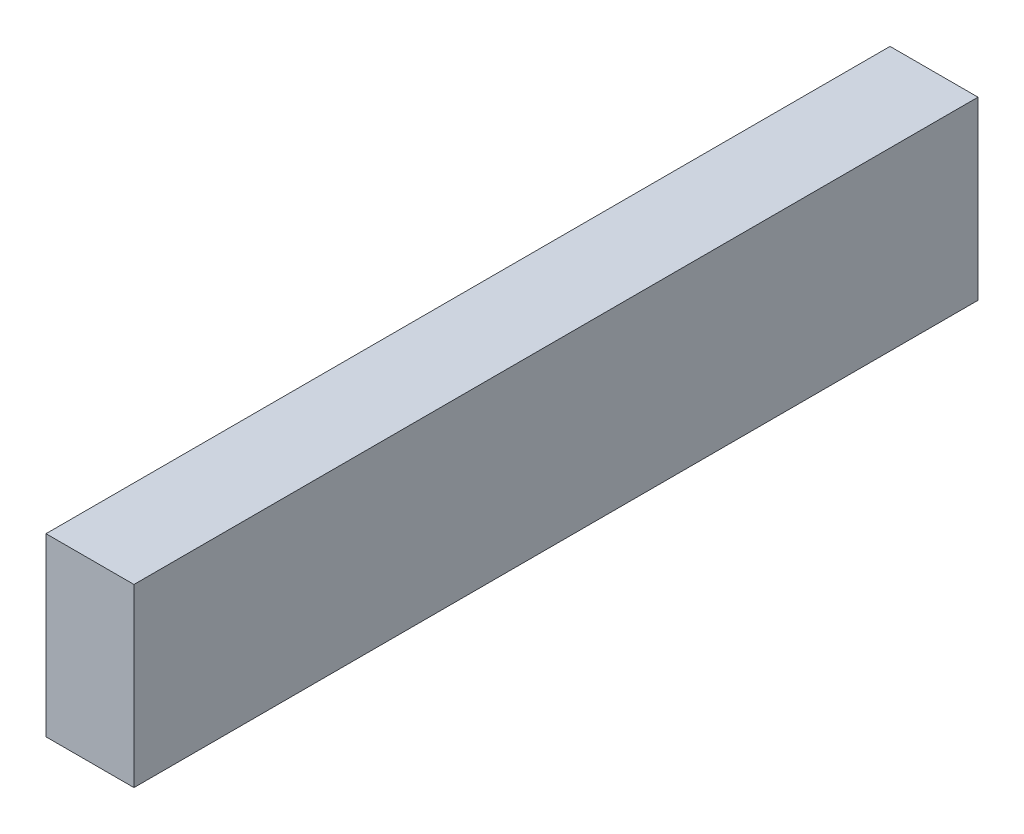
from build123d import *

# Parameters (mm, degrees)
SKETCH1_W           = 182.7784
SKETCH1_H           = 38.1
BOSS_EXTRUDE1_DEPTH = 19.05


with BuildPart() as part:
    # Sketch1 → Boss-Extrude1 (new body)
    with BuildSketch(Plane(origin=(0, 0, 0), x_dir=(0, 0, -1), z_dir=(1, 0, 0))):
        with Locations((51.679254854, 9.18456145)):
            Rectangle(SKETCH1_W, SKETCH1_H)
    extrude(amount=BOSS_EXTRUDE1_DEPTH)


solid = part.part
